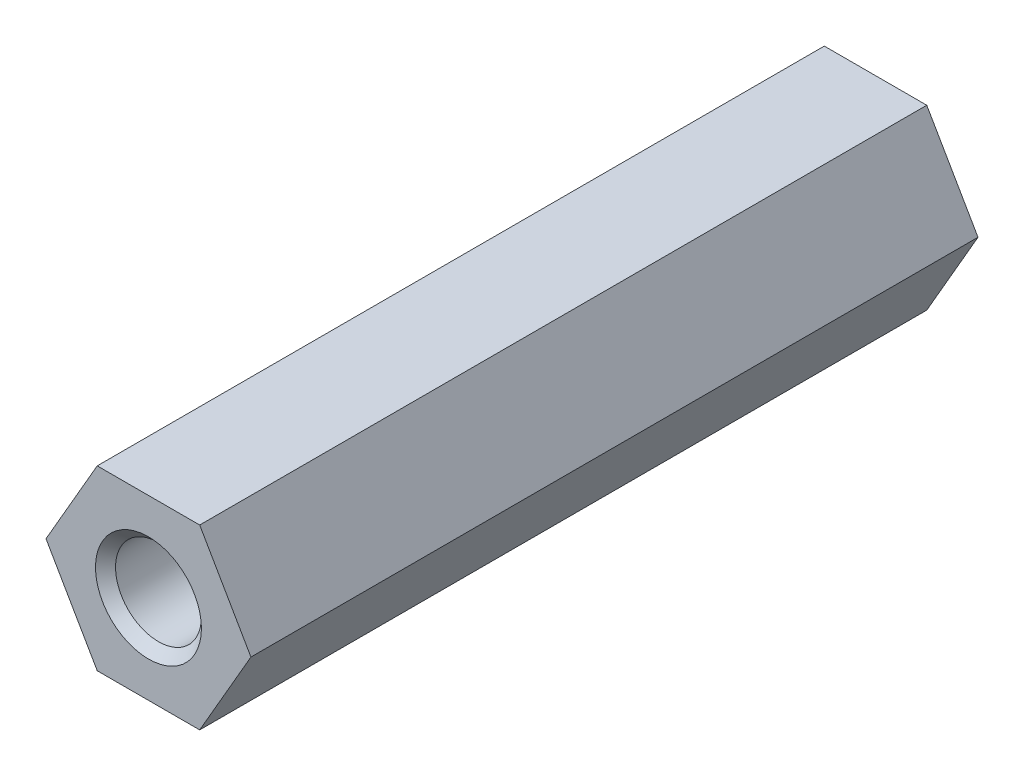
from build123d import *

# Parameters (mm, degrees)
BOSS_EXTRUDE1_DEPTH          = 25.4
F_3_0_3_DIAMETER_HOLE1_D     = 3
F_3_0_3_DIAMETER_HOLE1_DEPTH = 25.4
CHAMFER1_SIZE                = 0.35


with BuildPart() as part:
    # Sketch1 → Boss-Extrude1 (new body)
    with BuildSketch(Plane.XY.offset(25.4)):
        Polygon((-3.579571669, 0), (-1.789785834, -3.1), (1.789785834, -3.1), (3.579571669, 0), (1.789785834, 3.1), (-1.789785834, 3.1), align=None)
    extrude(amount=-BOSS_EXTRUDE1_DEPTH)

    # Ø3.0 (3) Diameter Hole1
    with Locations(Plane.XY.offset(25.4)):
        with Locations((0, 0)):
            Hole(F_3_0_3_DIAMETER_HOLE1_D / 2, depth=F_3_0_3_DIAMETER_HOLE1_DEPTH)

    # Chamfer1
    chamfer1_edges = [part.edges().sort_by_distance(p)[0] for p in [
        (1.5, 0, 25.4),
        (1.5, 0, 0),
    ]]
    chamfer(chamfer1_edges, length=CHAMFER1_SIZE)


solid = part.part
